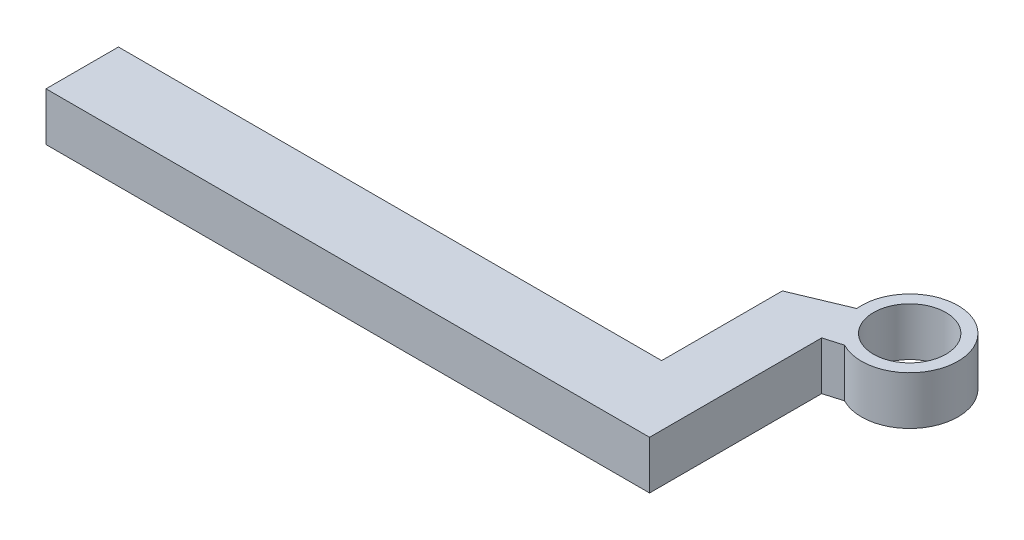
from build123d import *

# Parameters (mm, degrees)
BOSS_EXTRUDE4_DEPTH            = 40
CUT_EXTRUDE1_REACH             = 42
SKETCH6_R                      = 30
CUT_EXTRUDE1_DIRECTION_2_DEPTH = 1.0000001


with BuildPart() as part:
    # Sketch2 → Boss-Extrude4 (new body)
    with BuildSketch(Plane(origin=(0, 0, 0), x_dir=(1, 0, 0), z_dir=(0, 1, 0))):
        with BuildLine():
            Line((200, 30), (-250, 30))
            Line((-250, 30), (-250, -30))
            Line((-250, -30), (250, -30))
            Line((250, -30), (250, 30))
            Line((250, 30), (250, 112.573687244))
            add(Edge.make_bspline(
                [(250, 112.573687244), (257.32553359, 114.720346637), (264.651067179, 116.867006031)],
                knots=[0, 0, 0, 0.441237609, 0.441237609, 0.441237609], degree=2))
            ThreePointArc((264.651067179, 116.867006031), (316.316425408, 174.744880654), (243.415537745, 148.200235436))
            add(Edge.make_bspline(
                [(200, 130), (221.707768873, 139.100117718), (243.415537745, 148.200235436)],
                knots=[0, 0, 0, 0.816012756, 0.816012756, 0.816012756], degree=2))
            Line((200, 130), (200, 30))
        make_face()
    extrude(amount=BOSS_EXTRUDE4_DEPTH)

    # Sketch6 → Cut-Extrude1 (cut, up to next)
    with BuildSketch(Plane.XZ, mode=Mode.PRIVATE) as cut_extrude1_sk1:
        with Locations((283.204484122, -152.303861418)):
            Circle(SKETCH6_R)
    cut_extrude1_tool1 = extrude(cut_extrude1_sk1.sketch, amount=-CUT_EXTRUDE1_REACH, mode=Mode.PRIVATE) & part.part
    add(cut_extrude1_tool1.solids().sort_by_distance((283.204484, 0, -152.303861))[0], mode=Mode.SUBTRACT)

    # Sketch6 → Cut-Extrude1 direction 2 (cut)
    with BuildSketch(Plane.XZ):
        with Locations((283.204484122, -152.303861418)):
            Circle(SKETCH6_R)
    extrude(amount=CUT_EXTRUDE1_DIRECTION_2_DEPTH, mode=Mode.SUBTRACT)


solid = part.part
